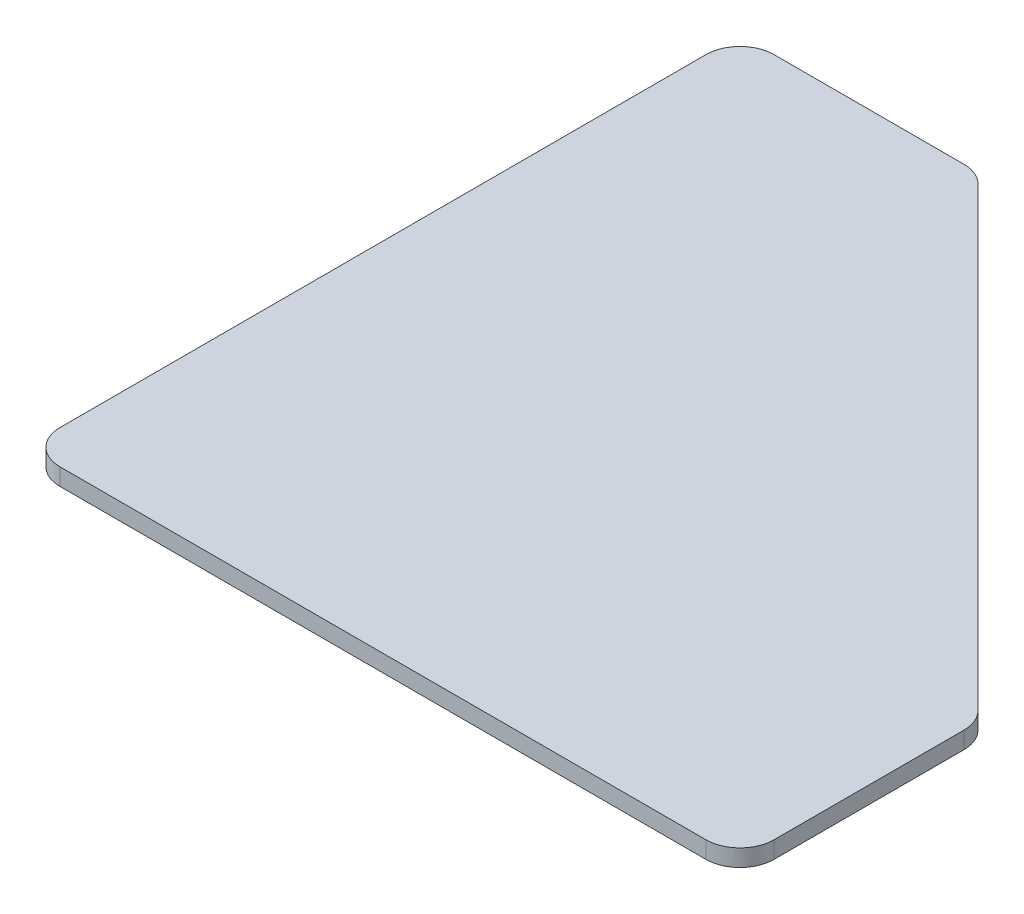
from build123d import *

# Parameters (mm, degrees)
BOSS_EXTRUDE1_DEPTH = 3.175
FILLET1_R           = 6.35


with BuildPart() as part:
    # Sketch1 → Boss-Extrude1 (new body)
    with BuildSketch(Plane(origin=(0, 0, 0), x_dir=(1, 0, 0), z_dir=(0, 1, 0))):
        Polygon((0, 0), (0, 133.35), (44.45, 133.35), (133.35, 44.45), (133.35, 0), align=None)
    extrude(amount=BOSS_EXTRUDE1_DEPTH)

    # Fillet1
    fillet1_edges = [part.edges().sort_by_distance(p)[0] for p in [
        (0, 1.5875, 0),
        (0, 1.5875, -133.35),
        (44.45, 1.5875, -133.35),
        (133.35, 1.5875, -44.45),
        (133.35, 1.5875, 0),
    ]]
    fillet(fillet1_edges, radius=FILLET1_R)


solid = part.part
